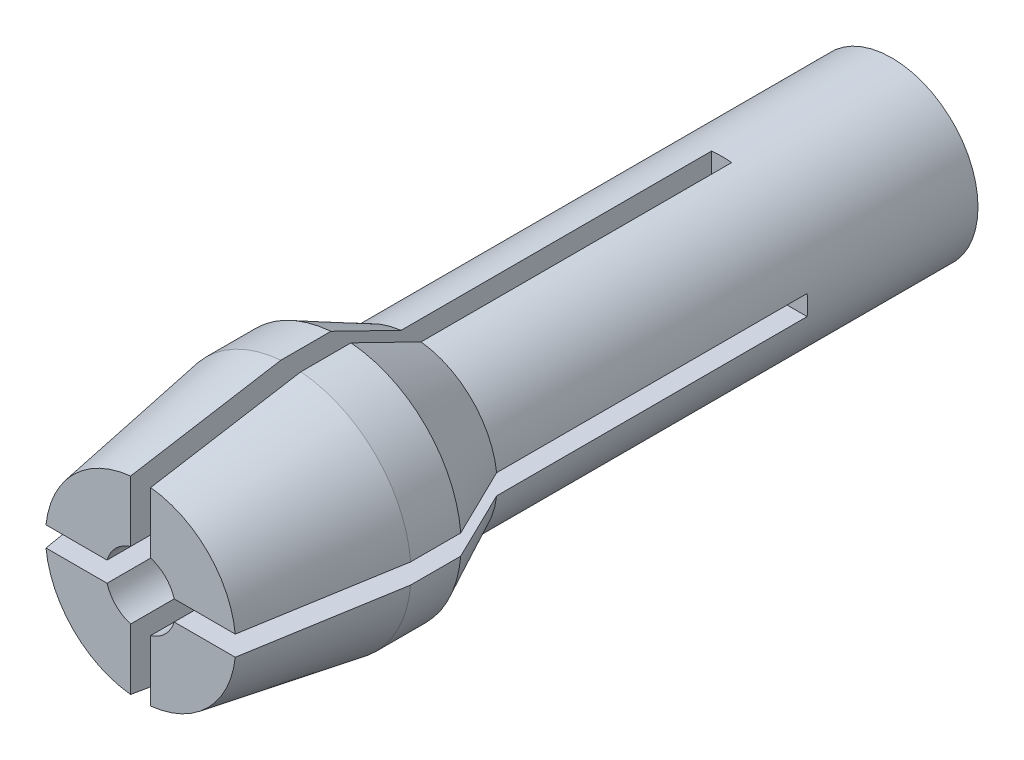
from build123d import *

# Parameters (mm, degrees)
SKETCH1_R           = 2.15
SKETCH1_R_2         = 0.875
BOSS_EXTRUDE1_DEPTH = 12
SKETCH2_R           = 3
SKETCH2_R_2         = 0.874277104
BOSS_EXTRUDE2_DEPTH = 6.75
CUT_EXTRUDE1_DEPTH  = 14.5


with BuildPart() as part:
    # Sketch1 → Boss-Extrude1 (new body)
    with BuildSketch(Plane.XY):
        Circle(SKETCH1_R)
        Circle(SKETCH1_R_2, mode=Mode.SUBTRACT)
    extrude(amount=BOSS_EXTRUDE1_DEPTH)

    # Sketch2 → Boss-Extrude2 (add)
    with BuildSketch(Plane.XY.offset(12)):
        Circle(SKETCH2_R)
        Circle(SKETCH2_R_2, mode=Mode.SUBTRACT)
    extrude(amount=BOSS_EXTRUDE2_DEPTH)

    # Sketch3 → Cut-Revolve1 (revolve, cut)
    with BuildSketch(Plane(origin=(0, 0, 0), x_dir=(1, 0, 0), z_dir=(0, 1, 0))):
        Polygon((2.15, -12), (3, -13.75), (4.254862661, -13.125400589), (3.126580546, -11.371696522), align=None)
        Polygon((2.375, -18.75), (3, -15), (5.751760011, -16.421813113), (4.254862661, -20.939605223), align=None)
    revolve(axis=Axis((0, 0, 0), (0, 0, 1)), mode=Mode.SUBTRACT)

    # Sketch4 → Cut-Extrude1 (cut)
    with BuildSketch(Plane.XY.offset(18.75)):
        Polygon((0, 3.340763125), (-0.25, 3.340763125), (-0.25, 0.464842209), (0.25, 0.464842209), (0.25, 3.340763125), align=None)
        Polygon((3.340763125, 0), (3.340763125, 0.25), (0.464842209, 0.25), (0.464842209, -0.25), (3.340763125, -0.25), align=None)
        Polygon((0, -3.340763125), (0.25, -3.340763125), (0.25, -0.464842209), (-0.25, -0.464842209), (-0.25, -3.340763125), align=None)
        Polygon((-3.340763125, 0), (-3.340763125, -0.25), (-0.464842209, -0.25), (-0.464842209, 0.25), (-3.340763125, 0.25), align=None)
    extrude(amount=-CUT_EXTRUDE1_DEPTH, mode=Mode.SUBTRACT)


solid = part.part
